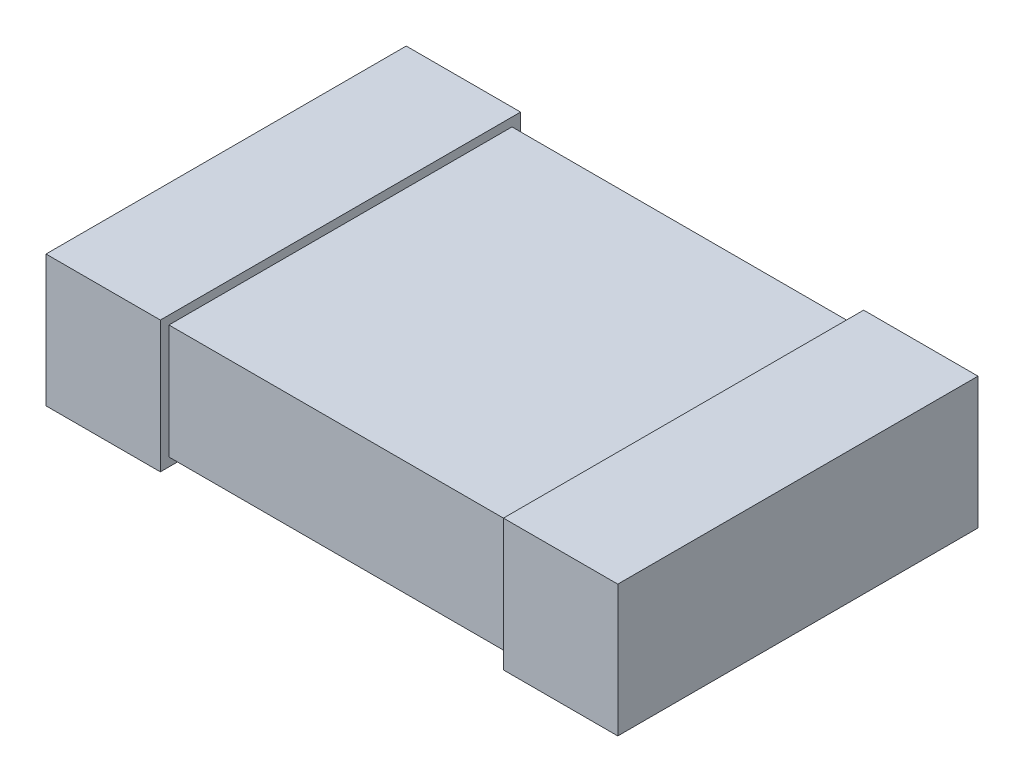
from build123d import *

# Parameters (mm, degrees)
SKETCH1_W           = 2
SKETCH1_H           = 1.2
EXTRUDE1_DEPTH      = 0.4
SKETCH2_W           = 0.4
SKETCH2_H           = 0.46
EXTRUDE2_DEPTH      = 0.63
EXTRUDE2_DEPTH_BACK = 0.63


with BuildPart() as part:
    # Sketch1 → Extrude1 (new body)
    with BuildSketch(Plane(origin=(0, 0, 0), x_dir=(1, 0, 0), z_dir=(0, 1, 0))):
        Rectangle(SKETCH1_W, SKETCH1_H)
    extrude(amount=EXTRUDE1_DEPTH)

    # Sketch2 → Extrude2 (add, two sides)
    with BuildSketch(Plane.XY) as extrude2_sk:
        with Locations((-0.8, 0.2)):
            Rectangle(SKETCH2_W, SKETCH2_H)
        with Locations((0.8, 0.2)):
            Rectangle(SKETCH2_W, SKETCH2_H)
    extrude(amount=EXTRUDE2_DEPTH)
    extrude(extrude2_sk.sketch, amount=-EXTRUDE2_DEPTH_BACK)


solid = part.part
